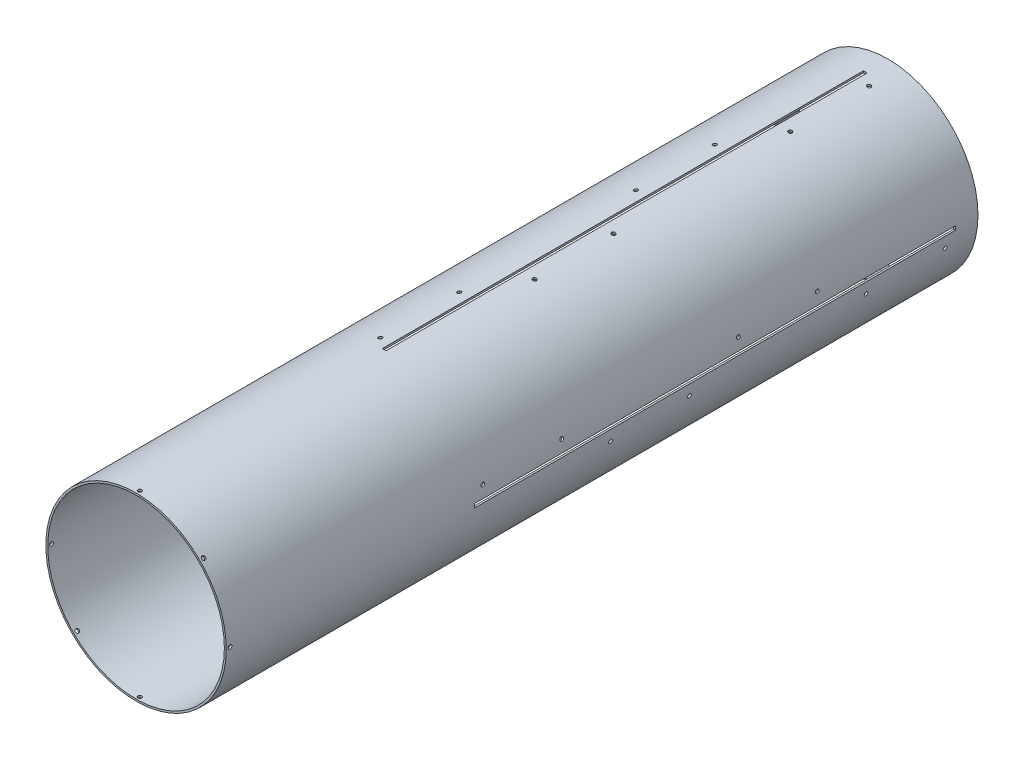
from build123d import *

# Parameters (mm, degrees)
SKETCH1_R           = 152.4
BOSS_EXTRUDE1_DEPTH = 1270
SKETCH2_R           = 149.225
CUT_EXTRUDE1_DEPTH  = 1270
SKETCH4_R           = 3.175
CUT_EXTRUDE2_DEPTH  = 300.482
CIRPATTERN1_COUNT   = 8
SKETCH6_W           = 6.35
SKETCH6_H           = 812.8
CUT_EXTRUDE3_DEPTH  = 152.4
CIRPATTERN2_COUNT   = 4
CUT_EXTRUDE4_START  = 0.961836
SKETCH7_R           = 3.175
CUT_EXTRUDE4_DEPTH  = 3.243886
CUT_EXTRUDE5_START  = 0.961836
SKETCH8_R           = 3.175
CUT_EXTRUDE5_DEPTH  = 3.243886
CIRPATTERN3_COUNT   = 4


with BuildPart() as part:
    # Sketch1 → Boss-Extrude1 (new body)
    with BuildSketch(Plane.XY):
        Circle(SKETCH1_R)
    extrude(amount=BOSS_EXTRUDE1_DEPTH)

    # Sketch2 → Cut-Extrude1 (cut)
    with BuildSketch(Plane.XY.offset(1270)):
        Circle(SKETCH2_R)
    extrude(amount=-CUT_EXTRUDE1_DEPTH, mode=Mode.SUBTRACT)

    # Sketch4 → Cut-Extrude2 (cut)
    with BuildSketch(Plane(origin=(0, 0, 0), x_dir=(1, 0, 0), z_dir=(0, 1, 0))):
        with Locations((0, -1263.65)):
            Circle(SKETCH4_R)
    cut_extrude2 = extrude(amount=-CUT_EXTRUDE2_DEPTH, mode=Mode.SUBTRACT)

    # CirPattern1: Cut-Extrude2 ×8 about axis
    cirpattern1_axis = Axis((0, 0, 1270), (0, 0, 1))
    for i in range(1, CIRPATTERN1_COUNT):
        add(cut_extrude2.rotate(cirpattern1_axis, i * 360 / CIRPATTERN1_COUNT), mode=Mode.SUBTRACT)

    # Sketch6 → Cut-Extrude3 (cut)
    with BuildSketch(Plane(origin=(0, 0, 0), x_dir=(1, 0, 0), z_dir=(0, 1, 0))):
        with Locations((0, -444.5)):
            Rectangle(SKETCH6_W, SKETCH6_H)
    cut_extrude3 = extrude(amount=-CUT_EXTRUDE3_DEPTH, mode=Mode.SUBTRACT)

    # CirPattern2: Cut-Extrude3 ×4 about axis
    cirpattern2_axis = Axis((0, 0, 0), (0, 0, 1))
    for i in range(1, CIRPATTERN2_COUNT):
        add(cut_extrude3.rotate(cirpattern2_axis, i * 360 / CIRPATTERN2_COUNT), mode=Mode.SUBTRACT)

    # Sketch7 → Cut-Extrude4 (cut)
    with BuildSketch(Plane(origin=(-20.367702071, 146.78799876, 850.9), x_dir=(0.990393205, 0.13827979, 0), z_dir=(-0.13827979, 0.990393205, 0)).offset(CUT_EXTRUDE4_START)):
        with Locations((-1.484470958, 149.225)):
            Circle(SKETCH7_R)
        with Locations((-1.484470958, 15.875)):
            Circle(SKETCH7_R)
        with Locations((-1.484470958, 447.675)):
            Circle(SKETCH7_R)
        with Locations((-1.484470958, 581.025)):
            Circle(SKETCH7_R)
    cut_extrude4 = extrude(amount=CUT_EXTRUDE4_DEPTH, mode=Mode.SUBTRACT)

    # Sketch8 → Cut-Extrude5 (cut)
    with BuildSketch(Plane(origin=(20.367702071, 146.78799876, 469.9), x_dir=(-0.990393205, 0.13827979, 0), z_dir=(0.13827979, 0.990393205, 0)).offset(CUT_EXTRUDE5_START)):
        with Locations((-1.484470958, -282.575)):
            Circle(SKETCH8_R)
        with Locations((-1.484470958, -415.925)):
            Circle(SKETCH8_R)
        with Locations((-1.484470958, 15.875)):
            Circle(SKETCH8_R)
        with Locations((-1.484470958, 149.225)):
            Circle(SKETCH8_R)
    cut_extrude5 = extrude(amount=CUT_EXTRUDE5_DEPTH, mode=Mode.SUBTRACT)

    # CirPattern3: Cut-Extrude4, Cut-Extrude5 ×4 about axis
    cirpattern3_axis = Axis((0, 0, 0), (0, 0, 1))
    for i in range(1, CIRPATTERN3_COUNT):
        add(cut_extrude4.rotate(cirpattern3_axis, i * 360 / CIRPATTERN3_COUNT), mode=Mode.SUBTRACT)
        add(cut_extrude5.rotate(cirpattern3_axis, i * 360 / CIRPATTERN3_COUNT), mode=Mode.SUBTRACT)


solid = part.part
